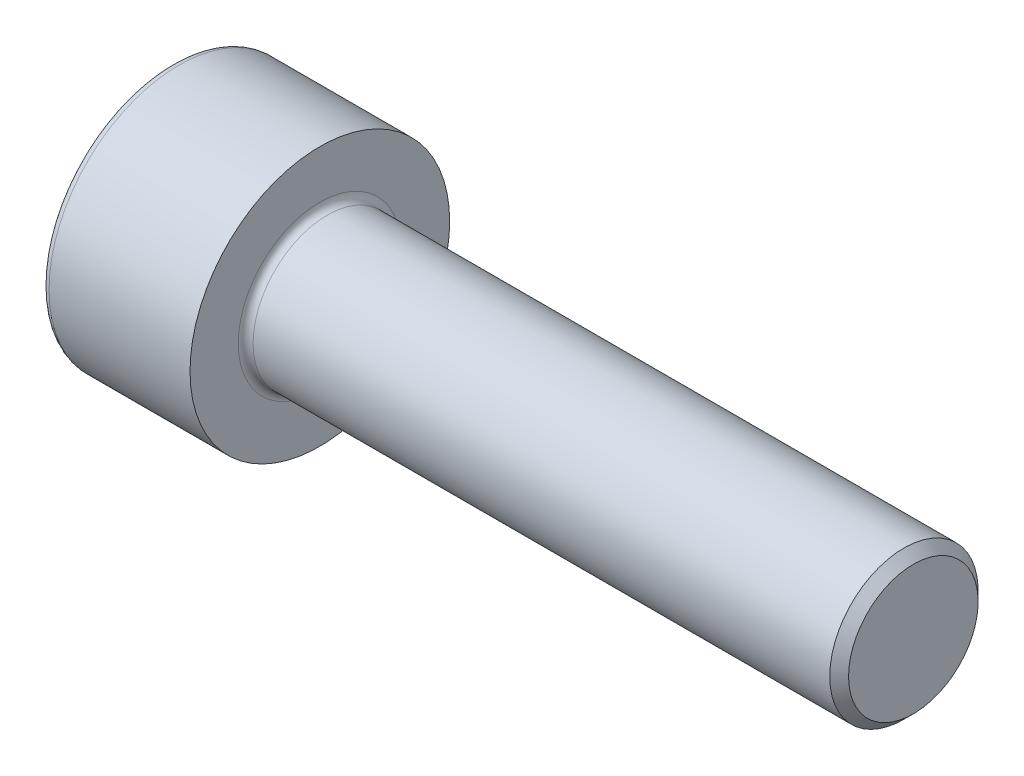
from build123d import *

# Parameters (mm, degrees)
CUT_EXTRUDE1_DEPTH = 2


with BuildPart() as part:
    # Sketch1 → Revolve1 (revolve)
    with BuildSketch(Plane.XY):
        with BuildLine():
            Line((15.7465, 2), (0.2, 2))
            ThreePointArc((0.2, 2), (0.058578644, 2.058578644), (0, 2.2))
            Line((0, 2.2), (0, 3.5))
            Line((0, 3.5), (-3.8, 3.5))
            ThreePointArc((-3.8, 3.5), (-3.941421356, 3.441421356), (-4, 3.3))
            Line((-4, 3.3), (-4, 0))
            Line((-4, 0), (16, 0))
            Line((16, 0), (16, 1.7465))
            Line((16, 1.7465), (15.7465, 2))
        make_face()
    revolve(axis=Axis((-4, 0, 0), (1, 0, 0)))

    # Sketch2 → Cut-Extrude1 (cut)
    with BuildSketch(Plane.ZY.offset(4)):
        Polygon((1.535, 0.886232663), (0, 1.772465326), (-1.535, 0.886232663), (-1.535, -0.886232663), (0, -1.772465326), (1.535, -0.886232663), align=None)
    extrude(amount=-CUT_EXTRUDE1_DEPTH, mode=Mode.SUBTRACT)


solid = part.part
